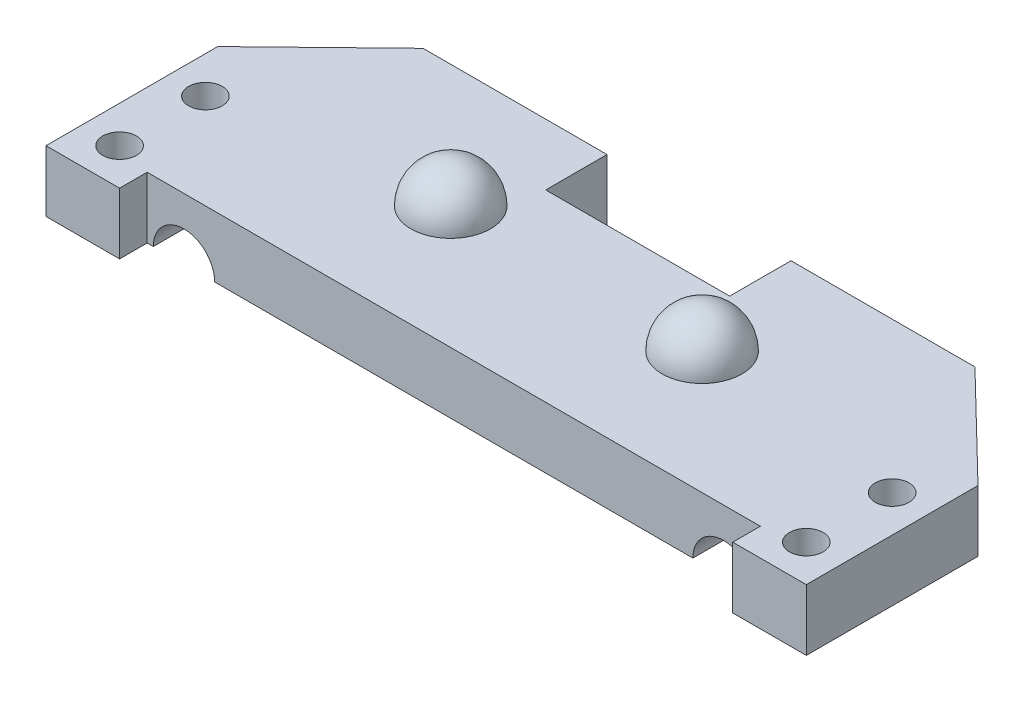
from build123d import *

# Parameters (mm, degrees)
SKETCH1_W               = 45
SKETCH1_H               = 20
BRACKETBASE_DEPTH       = 5
SKETCH3_R               = 1.375
MOUNTINGTABS_DEPTH      = 5
SKETCH4_W               = 15
SKETCH4_H               = 5
HEADERSLOT_DEPTH        = 13.625
SKETCH6_R               = 2.5
CUT_EXTRUDE1_DEPTH      = 3.25
CUT_EXTRUDE1_DEPTH_BACK = 21


with BuildPart() as part:
    # Sketch1 → bracketBase (new body)
    with BuildSketch(Plane(origin=(0, 0, 0), x_dir=(1, 0, 0), z_dir=(0, 1, 0))):
        with Locations((22.5, 10)):
            Rectangle(SKETCH1_W, SKETCH1_H)
    extrude(amount=BRACKETBASE_DEPTH)

    # Sketch2 → ballPoint1 (revolve)
    with BuildSketch(Plane(origin=(0, 5, 0), x_dir=(1, 0, 0), z_dir=(0, 1, 0))):
        with BuildLine():
            Line((12.25, 13.25), (12.25, 6.75))
            ThreePointArc((12.25, 6.75), (9, 10), (12.25, 13.25))
        make_face()
    ballpoint1 = revolve(axis=Axis((12.25, 5, -13.25), (0, 0, 1)))

    # Mirror1: ballPoint1 across plane
    add(ballpoint1.mirror(Plane.ZY.offset(-22.5)))

    # Sketch3 → mountingTabs (add)
    with BuildSketch(Plane.XZ):
        Polygon((45, -20), (53.5, -11.75), (53.5, 2.25), (47.5, 2.25), (47.5, 0), (45, 0), align=None)
        with Locations((50.5, -0.75)):
            Circle(SKETCH3_R, mode=Mode.SUBTRACT)
        with Locations((50.5, -7.75)):
            Circle(SKETCH3_R, mode=Mode.SUBTRACT)
        Polygon((-2.5, 0), (0, 0), (0, -20), (-8.5, -11.75), (-8.5, 2.25), (-2.5, 2.25), align=None)
        with Locations((-5.5, -0.75)):
            Circle(SKETCH3_R, mode=Mode.SUBTRACT)
        with Locations((-5.5, -7.75)):
            Circle(SKETCH3_R, mode=Mode.SUBTRACT)
    extrude(amount=-MOUNTINGTABS_DEPTH)

    # Sketch4 → headerSlot (cut)
    with BuildSketch(Plane.XZ):
        with Locations((22.5, -17.5)):
            Rectangle(SKETCH4_W, SKETCH4_H)
    extrude(amount=-HEADERSLOT_DEPTH, mode=Mode.SUBTRACT)

    # Sketch6 → Cut-Extrude1 (cut, two sides)
    with BuildSketch(Plane.XY) as cut_extrude1_sk:
        with Locations((44.5, 0)):
            Circle(SKETCH6_R)
        with Locations((0.5, 0)):
            Circle(SKETCH6_R)
    extrude(amount=CUT_EXTRUDE1_DEPTH, mode=Mode.SUBTRACT)
    extrude(cut_extrude1_sk.sketch, amount=-CUT_EXTRUDE1_DEPTH_BACK, mode=Mode.SUBTRACT)


solid = part.part
